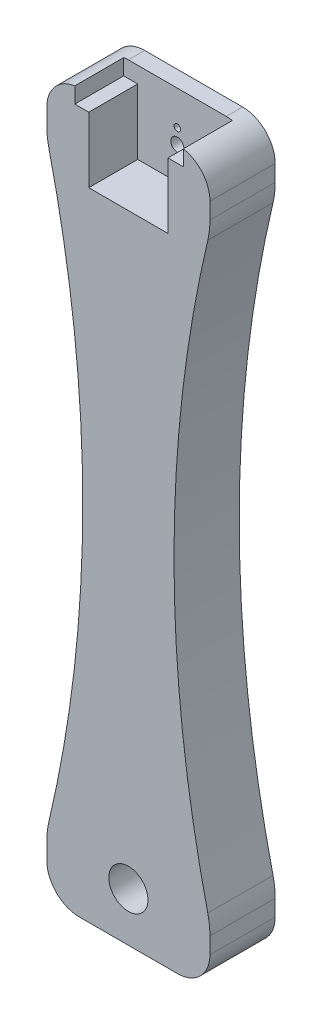
from build123d import *

# Parameters (mm, degrees)
SKETCH1_W           = 50
SKETCH1_H           = 220
BOSS_EXTRUDE1_DEPTH = 20
SKETCH2_R           = 2
SKETCH2_R_2         = 6
CUT_EXTRUDE2_DEPTH  = 34
FILLET2_R           = 10
CUT_EXTRUDE3_DEPTH  = 15
SKETCH7_R           = 1
CUT_EXTRUDE4_DEPTH  = 15
CUT_EXTRUDE6_DEPTH  = 15
CUT_EXTRUDE7_DEPTH  = 53


with BuildPart() as part:
    # Sketch1 → Boss-Extrude1 (new body)
    with BuildSketch(Plane.XY):
        with Locations((25, -110)):
            Rectangle(SKETCH1_W, SKETCH1_H)
    extrude(amount=BOSS_EXTRUDE1_DEPTH)

    # Sketch2 → Cut-Extrude2 (cut)
    with BuildSketch(Plane.XY.offset(20)):
        with Locations((25, -15)):
            Circle(SKETCH2_R)
        with Locations((25, -205)):
            Circle(SKETCH2_R_2)
    extrude(amount=-CUT_EXTRUDE2_DEPTH, mode=Mode.SUBTRACT)

    # Fillet2
    fillet2_edges = [part.edges().sort_by_distance(p)[0] for p in [
        (0, 0, 10),
        (50, 0, 10),
        (50, -220, 10),
        (0, -220, 10),
    ]]
    fillet(fillet2_edges, radius=FILLET2_R)

    # Sketch4 → Cut-Extrude3 (cut)
    with BuildSketch(Plane.XY.offset(20)):
        Polygon((25, -25), (37.14, -25), (37.14, 0), (12.86, 0), (12.86, -25), align=None)
    extrude(amount=-CUT_EXTRUDE3_DEPTH, mode=Mode.SUBTRACT)

    # Sketch7 → Cut-Extrude4 (cut)
    with BuildSketch(Plane(origin=(0, 0, 0), x_dir=(-1, 0, 0), z_dir=(0, 0, -1))):
        with Locations((-25, -10.5)):
            Circle(SKETCH7_R)
        with Locations((-25, -19.5)):
            Circle(SKETCH7_R)
    extrude(amount=-CUT_EXTRUDE4_DEPTH, mode=Mode.SUBTRACT)

    # Sketch8 → Cut-Extrude6 (cut)
    with BuildSketch(Plane.XY.offset(20)):
        with BuildLine():
            Line((12.86, -4.956404509), (37.14, -4.956404509))
            Line((37.14, -4.956404509), (37.14, 0))
            Line((37.14, 0), (40, 0))
            ThreePointArc((40, 0), (40.933059212, -0.043625132), (41.857977457, -0.174119899))
            Line((41.857977457, -0.174119899), (41.857977457, 3.191267917))
            Line((41.857977457, 3.191267917), (8.577977457, 3.191267917))
            Line((8.577977457, 3.191267917), (8.577977457, -0.101623775))
            ThreePointArc((8.577977457, -0.101623775), (9.287175424, -0.025438299), (10, 0))
            Line((10, 0), (12.86, 0))
            Line((12.86, 0), (12.86, -4.956404509))
        make_face()
        with BuildLine():
            Line((8.577977457, -4.956404509), (12.86, -4.956404509))
            Line((12.86, -4.956404509), (12.86, 0))
            Line((12.86, 0), (10, 0))
            ThreePointArc((10, 0), (9.287175424, -0.025438299), (8.577977457, -0.101623775))
            Line((8.577977457, -0.101623775), (8.577977457, -4.956404509))
        make_face()
        with BuildLine():
            Line((37.14, 0), (37.14, -4.956404509))
            Line((37.14, -4.956404509), (41.857977457, -4.956404509))
            Line((41.857977457, -4.956404509), (41.857977457, -0.174119899))
            ThreePointArc((41.857977457, -0.174119899), (40.933059212, -0.043625132), (40, 0))
            Line((40, 0), (37.14, 0))
        make_face()
    extrude(amount=-CUT_EXTRUDE6_DEPTH, mode=Mode.SUBTRACT)

    # Sketch9 → Cut-Extrude7 (cut)
    with BuildSketch(Plane.XY.offset(20)):
        with BuildLine():
            ThreePointArc((49.336156478, -199.277108434), (49.833484572, -202.119367426), (50, -205))
            Line((50, -205), (50, -202.054385429))
            Line((50, -202.054385429), (50, -15))
            ThreePointArc((50, -15), (49.833484572, -17.880632574), (49.336156478, -20.722891566))
            ThreePointArc((49.336156478, -20.722891566), (38.980197534, -110), (49.336156478, -199.277108434))
        make_face()
        with BuildLine():
            Line((0, -19.137020496), (0, -205))
            ThreePointArc((0, -205), (0.166515428, -202.119367426), (0.663843522, -199.277108434))
            ThreePointArc((0.663843522, -199.277108434), (11.019802466, -110), (0.663843522, -20.722891566))
            ThreePointArc((0.663843522, -20.722891566), (0.166515428, -17.880632574), (0, -15))
            Line((0, -15), (0, -19.137020496))
        make_face()
    extrude(amount=-CUT_EXTRUDE7_DEPTH, mode=Mode.SUBTRACT)


solid = part.part
